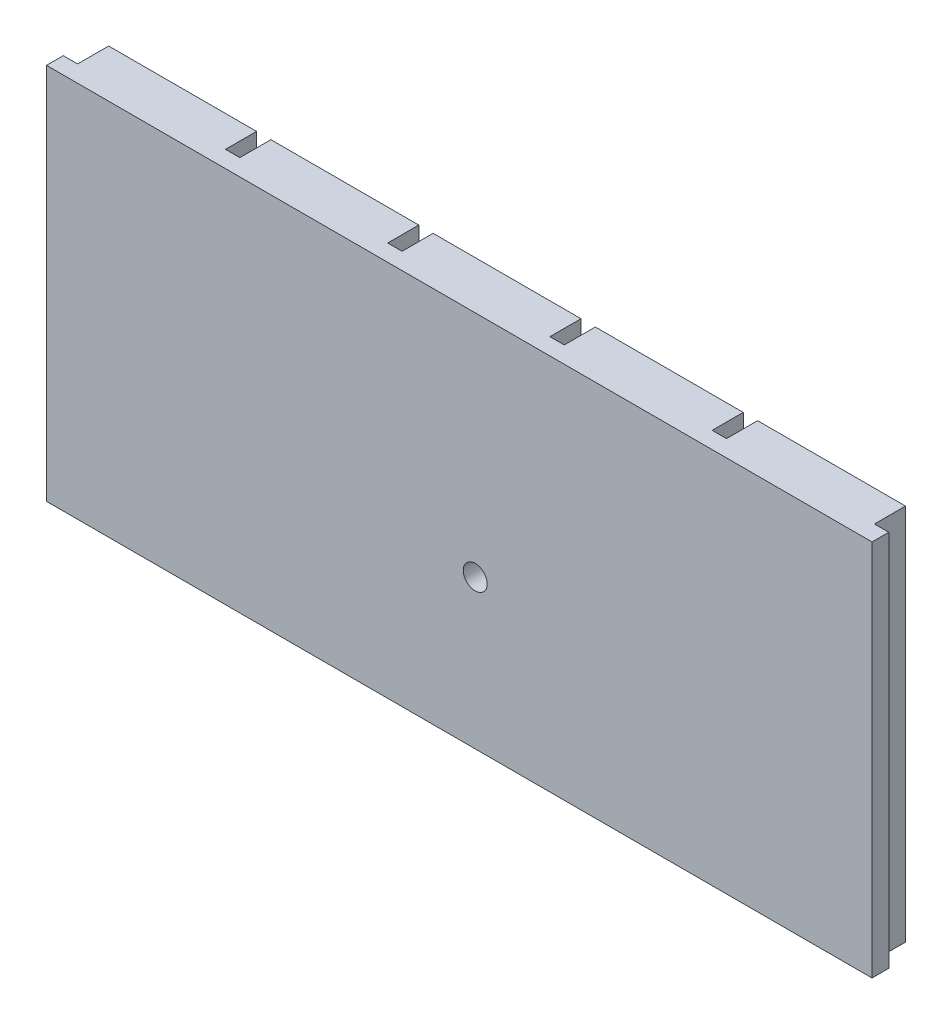
from build123d import *

# Parameters (mm, degrees)
SKETCH1_W           = 172.688303012
SKETCH1_H           = 79
SKETCH1_R           = 2.5
BOSS_EXTRUDE1_DEPTH = 10
CUT_EXTRUDE1_REACH  = 81
SKETCH2_W           = 3
SKETCH2_H           = 6.5


with BuildPart() as part:
    # Sketch1 → Boss-Extrude1 (new body)
    with BuildSketch(Plane.XY):
        Rectangle(SKETCH1_W, SKETCH1_H)
        with Locations((3.337204705, -8.386778216)):
            Circle(SKETCH1_R, mode=Mode.SUBTRACT)
    extrude(amount=BOSS_EXTRUDE1_DEPTH)

    # Sketch2 → Cut-Extrude1 (cut, up to next)
    with BuildSketch(Plane(origin=(0, 39.5, 0), x_dir=(1, 0, 0), z_dir=(0, 1, 0)), mode=Mode.PRIVATE) as cut_extrude1_sk1:
        with Locations((84.844151506, -3.25)):
            Rectangle(SKETCH2_W, SKETCH2_H)
    cut_extrude1_tool1 = extrude(cut_extrude1_sk1.sketch, amount=-CUT_EXTRUDE1_REACH, mode=Mode.PRIVATE) & part.part
    add(cut_extrude1_tool1.solids().sort_by_distance((84.844152, 39.5, 3.25))[0], mode=Mode.SUBTRACT)
    # Sketch2 → Cut-Extrude1 (cut, up to next)
    with BuildSketch(Plane(origin=(0, 39.5, 0), x_dir=(1, 0, 0), z_dir=(0, 1, 0)), mode=Mode.PRIVATE) as cut_extrude1_sk2:
        with Locations((50.906490903, -3.25)):
            Rectangle(SKETCH2_W, SKETCH2_H)
    cut_extrude1_tool2 = extrude(cut_extrude1_sk2.sketch, amount=-CUT_EXTRUDE1_REACH, mode=Mode.PRIVATE) & part.part
    add(cut_extrude1_tool2.solids().sort_by_distance((50.906491, 39.5, 3.25))[0], mode=Mode.SUBTRACT)
    # Sketch2 → Cut-Extrude1 (cut, up to next)
    with BuildSketch(Plane(origin=(0, 39.5, 0), x_dir=(1, 0, 0), z_dir=(0, 1, 0)), mode=Mode.PRIVATE) as cut_extrude1_sk3:
        with Locations((16.968830301, -3.25)):
            Rectangle(SKETCH2_W, SKETCH2_H)
    cut_extrude1_tool3 = extrude(cut_extrude1_sk3.sketch, amount=-CUT_EXTRUDE1_REACH, mode=Mode.PRIVATE) & part.part
    add(cut_extrude1_tool3.solids().sort_by_distance((16.96883, 39.5, 3.25))[0], mode=Mode.SUBTRACT)
    # Sketch2 → Cut-Extrude1 (cut, up to next)
    with BuildSketch(Plane(origin=(0, 39.5, 0), x_dir=(1, 0, 0), z_dir=(0, 1, 0)), mode=Mode.PRIVATE) as cut_extrude1_sk4:
        with Locations((-16.968830301, -3.25)):
            Rectangle(SKETCH2_W, SKETCH2_H)
    cut_extrude1_tool4 = extrude(cut_extrude1_sk4.sketch, amount=-CUT_EXTRUDE1_REACH, mode=Mode.PRIVATE) & part.part
    add(cut_extrude1_tool4.solids().sort_by_distance((-16.96883, 39.5, 3.25))[0], mode=Mode.SUBTRACT)
    # Sketch2 → Cut-Extrude1 (cut, up to next)
    with BuildSketch(Plane(origin=(0, 39.5, 0), x_dir=(1, 0, 0), z_dir=(0, 1, 0)), mode=Mode.PRIVATE) as cut_extrude1_sk5:
        with Locations((-50.906490903, -3.25)):
            Rectangle(SKETCH2_W, SKETCH2_H)
    cut_extrude1_tool5 = extrude(cut_extrude1_sk5.sketch, amount=-CUT_EXTRUDE1_REACH, mode=Mode.PRIVATE) & part.part
    add(cut_extrude1_tool5.solids().sort_by_distance((-50.906491, 39.5, 3.25))[0], mode=Mode.SUBTRACT)
    # Sketch2 → Cut-Extrude1 (cut, up to next)
    with BuildSketch(Plane(origin=(0, 39.5, 0), x_dir=(1, 0, 0), z_dir=(0, 1, 0)), mode=Mode.PRIVATE) as cut_extrude1_sk6:
        with Locations((-84.844151506, -3.25)):
            Rectangle(SKETCH2_W, SKETCH2_H)
    cut_extrude1_tool6 = extrude(cut_extrude1_sk6.sketch, amount=-CUT_EXTRUDE1_REACH, mode=Mode.PRIVATE) & part.part
    add(cut_extrude1_tool6.solids().sort_by_distance((-84.844152, 39.5, 3.25))[0], mode=Mode.SUBTRACT)


solid = part.part
